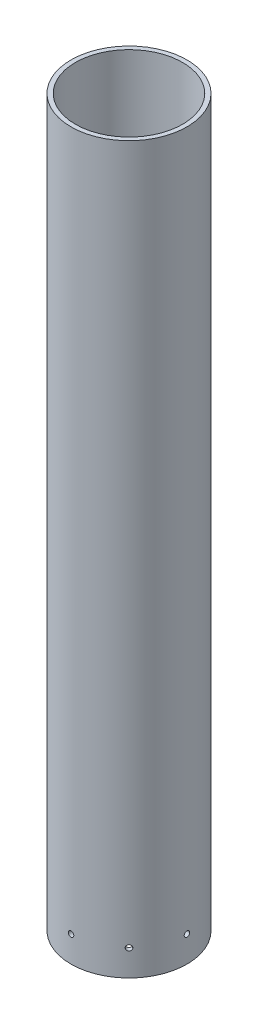
from build123d import *

# Parameters (mm, degrees)
SKETCH1_R           = 40
SKETCH1_R_2         = 36.95
BOSS_EXTRUDE1_DEPTH = 500
SKETCH2_R           = 1.9
CUT_EXTRUDE1_DEPTH  = 66
CIRPATTERN2_COUNT   = 8


with BuildPart() as part:
    # Sketch1 → Boss-Extrude1 (new body)
    with BuildSketch(Plane(origin=(0, 0, 0), x_dir=(1, 0, 0), z_dir=(0, 1, 0))):
        Circle(SKETCH1_R)
        Circle(SKETCH1_R_2, mode=Mode.SUBTRACT)
    extrude(amount=BOSS_EXTRUDE1_DEPTH)

    # Sketch2 → Cut-Extrude1 (cut)
    with BuildSketch(Plane.XY):
        with Locations((0, 18)):
            Circle(SKETCH2_R)
    cut_extrude1 = extrude(amount=-CUT_EXTRUDE1_DEPTH, mode=Mode.SUBTRACT)

    # CirPattern2: Cut-Extrude1 ×8 about axis
    cirpattern2_axis = Axis((0, 500, 0), (0, -1, 0))
    for i in range(1, CIRPATTERN2_COUNT):
        add(cut_extrude1.rotate(cirpattern2_axis, i * 360 / CIRPATTERN2_COUNT), mode=Mode.SUBTRACT)


solid = part.part
